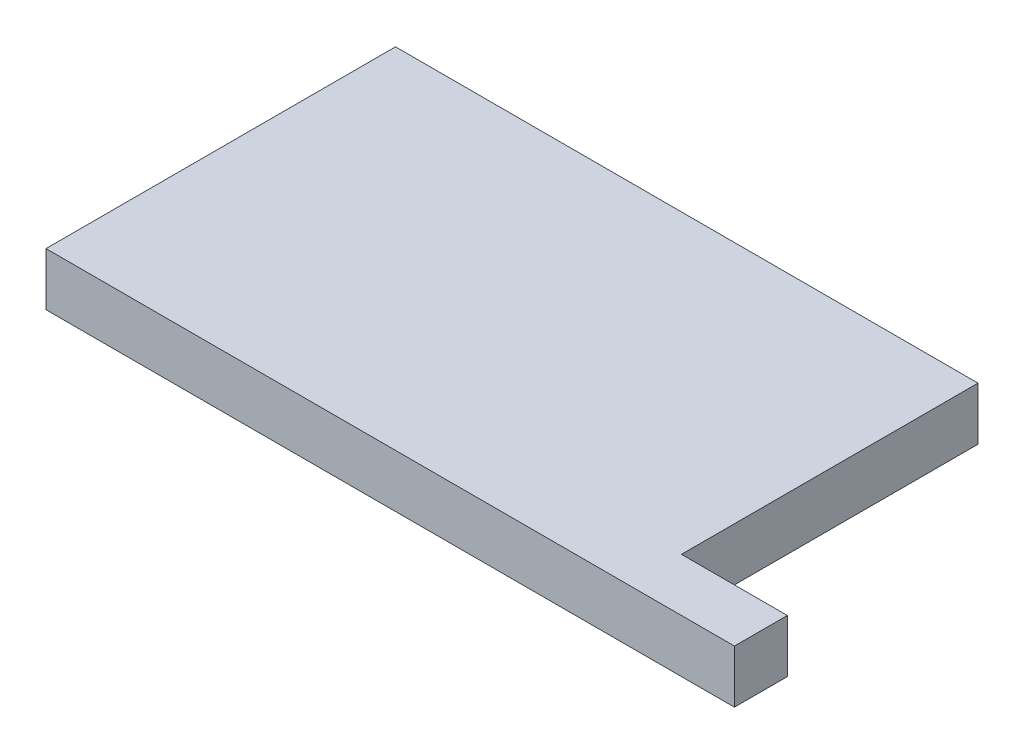
from build123d import *

# Parameters (mm, degrees)
SKETCH1_W           = 55
SKETCH1_H           = 33
SKETCH1_W_2         = 10
SKETCH1_H_2         = 5
BOSS_EXTRUDE1_DEPTH = 2.5


with BuildPart() as part:
    # Sketch1 → Boss-Extrude1 (new body, symmetric)
    with BuildSketch(Plane(origin=(0, 0, 0), x_dir=(1, 0, 0), z_dir=(0, 1, 0))):
        Rectangle(SKETCH1_W, SKETCH1_H)
        with Locations((32.5, -14)):
            Rectangle(SKETCH1_W_2, SKETCH1_H_2)
    extrude(amount=BOSS_EXTRUDE1_DEPTH, both=True)


solid = part.part
